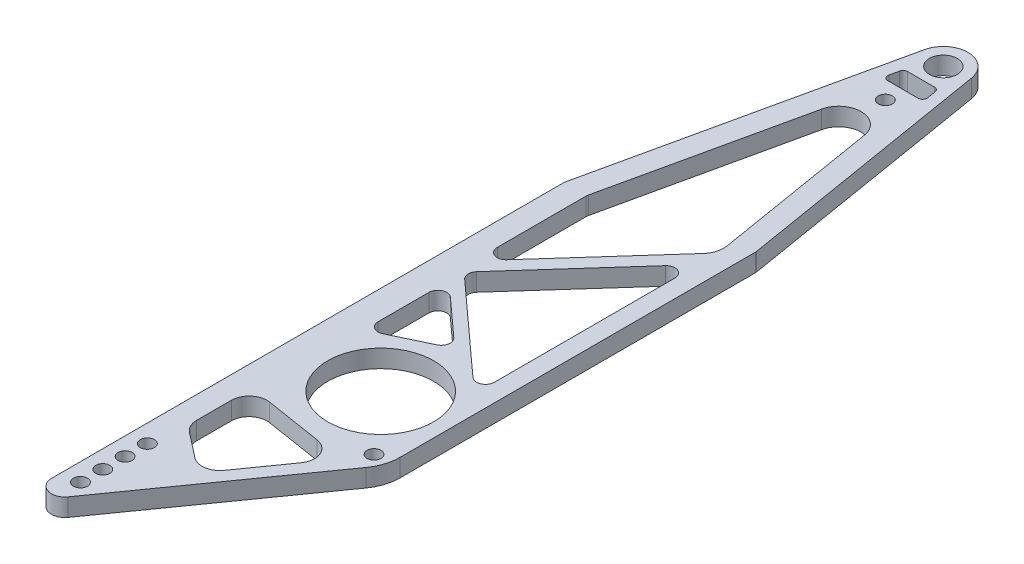
from build123d import *

# Parameters (mm, degrees)
SKETCH11_R          = 3.96875
SKETCH11_R_2        = 15.08125
SKETCH11_R_3        = 2
BOSS_EXTRUDE2_DEPTH = 5.08


with BuildPart() as part:
    # Sketch11 → Boss-Extrude2 (new body)
    with BuildSketch(Plane(origin=(0, 0, 0), x_dir=(1, 0, 0), z_dir=(0, 1, 0))):
        with BuildLine():
            Line((19.05, -173.758834345), (19.05, -72.598586407))
            ThreePointArc((19.05, -72.598586407), (19.041478453, -72.390699795), (19.015970989, -72.184208077))
            Line((19.015970989, -72.184208077), (6.891420221, 1.139540409))
            ThreePointArc((6.891420221, 1.139540409), (0.187396777, 6.982485764), (-6.820377584, 1.507539257))
            Line((-6.820377584, 1.507539257), (-25.340137303, -82.279170439))
            ThreePointArc((-25.340137303, -82.279170439), (-25.384989975, -82.551639086), (-25.4, -82.827366533))
            Line((-25.4, -82.827366533), (-25.4, -177.8))
            Line((-25.4, -177.8), (-25.4, -228.6))
            ThreePointArc((-25.4, -228.6), (-22.745272537, -232.230626029), (-18.480606107, -230.801765114))
            Line((-18.480606107, -230.801765114), (16.71464631, -181.098051393))
            ThreePointArc((16.71464631, -181.098051393), (18.452086765, -177.609742801), (19.05, -173.758834345))
        make_face()
        Circle(SKETCH11_R, mode=Mode.SUBTRACT)
        with Locations((0, -160.246508934)):
            Circle(SKETCH11_R_2, mode=Mode.SUBTRACT)
        with Locations((-20.32, -225.425)):
            Circle(SKETCH11_R_3, mode=Mode.SUBTRACT)
        with Locations((-20.32, -219.075)):
            Circle(SKETCH11_R_3, mode=Mode.SUBTRACT)
        with Locations((-20.32, -212.725)):
            Circle(SKETCH11_R_3, mode=Mode.SUBTRACT)
        with Locations((-20.32, -206.375)):
            Circle(SKETCH11_R_3, mode=Mode.SUBTRACT)
        with Locations((0, -16.51)):
            Circle(SKETCH11_R_3, mode=Mode.SUBTRACT)
        with Locations((14.605, -176.756508934)):
            Circle(SKETCH11_R_3, mode=Mode.SUBTRACT)
        with BuildLine():
            Line((11.940278596, -80.334093652), (-14.464036902, -109.837128051))
            ThreePointArc((-14.464036902, -109.837128051), (-17.263416449, -110.515885849), (-18.896731016, -108.143224574))
            Line((-18.896731016, -108.143224574), (-18.896731016, -82.827366533))
            ThreePointArc((-18.896731016, -82.827366533), (-18.881720992, -82.551639086), (-18.83686832, -82.279170439))
            Line((-18.83686832, -82.279170439), (-6.80244992, -27.833306339))
            ThreePointArc((-6.80244992, -27.833306339), (-0.402909414, -22.833553189), (5.719243979, -28.169365038))
            Line((5.719243979, -28.169365038), (13.473470783, -75.063389134))
            ThreePointArc((13.473470783, -75.063389134), (13.305815609, -77.87296697), (11.940278596, -80.334093652))
        make_face(mode=Mode.SUBTRACT)
        with BuildLine():
            Line((13.97, -141.812492878), (13.97, -90.426050798))
            ThreePointArc((13.97, -90.426050798), (12.336685433, -88.053389523), (9.537305885, -88.732147321))
            Line((9.537305885, -88.732147321), (-15.843545445, -117.091607347))
            ThreePointArc((-15.843545445, -117.091607347), (-16.487420873, -118.917476564), (-15.657551613, -120.666673802))
            Line((-15.657551613, -120.666673802), (9.723299718, -143.693655856))
            ThreePointArc((9.723299718, -143.693655856), (12.458732541, -144.134842843), (13.97, -141.812492878))
        make_face(mode=Mode.SUBTRACT)
        with BuildLine():
            Line((-13.279299718, -127.111337727), (-2.809524218, -136.610125984))
            ThreePointArc((-2.809524218, -136.610125984), (-2.003545388, -138.86283126), (-3.426980373, -140.785879825))
            Line((-3.426980373, -140.785879825), (-13.896755873, -145.755890669))
            ThreePointArc((-13.896755873, -145.755890669), (-16.343372447, -145.60819059), (-17.526, -143.461299805))
            Line((-17.526, -143.461299805), (-17.526, -128.992500705))
            ThreePointArc((-17.526, -128.992500705), (-16.014732541, -126.67015074), (-13.279299718, -127.111337727))
        make_face(mode=Mode.SUBTRACT)
        with BuildLine():
            Line((6.282161105, -189.238159376), (-2.779804772, -202.035719466))
            ThreePointArc((-2.779804772, -202.035719466), (-6.184281083, -204.125642303), (-10.047215475, -203.107814076))
            Line((-10.047215475, -203.107814076), (-17.09155218, -197.621171408))
            ThreePointArc((-17.09155218, -197.621171408), (-18.534202289, -195.843739158), (-19.05, -193.613389978))
            Line((-19.05, -193.613389978), (-19.05, -183.748869713))
            ThreePointArc((-19.05, -183.748869713), (-17.268890157, -179.885746141), (-13.174518217, -178.731538875))
            Line((-13.174518217, -178.731538875), (2.931784364, -181.28514172))
            ThreePointArc((2.931784364, -181.28514172), (6.817844364, -184.330274157), (6.282161105, -189.238159376))
        make_face(mode=Mode.SUBTRACT)
        with BuildLine():
            Line((3.834506832, -6.35), (-3.834506832, -6.35))
            ThreePointArc((-3.834506832, -6.35), (-4.629741225, -6.629796859), (-5.074575483, -7.345901953))
            Line((-5.074575483, -7.345901953), (-5.636003302, -9.885901953))
            ThreePointArc((-5.636003302, -9.885901953), (-5.386137791, -10.955234393), (-4.395934651, -11.43))
            Line((-4.395934651, -11.43), (4.254512077, -11.43))
            ThreePointArc((4.254512077, -11.43), (5.223023884, -10.981513774), (5.507497571, -9.952810835))
            Line((5.507497571, -9.952810835), (5.087492326, -7.412810835))
            ThreePointArc((5.087492326, -7.412810835), (4.656020605, -6.651488193), (3.834506832, -6.35))
        make_face(mode=Mode.SUBTRACT)
    extrude(amount=-BOSS_EXTRUDE2_DEPTH)


solid = part.part
